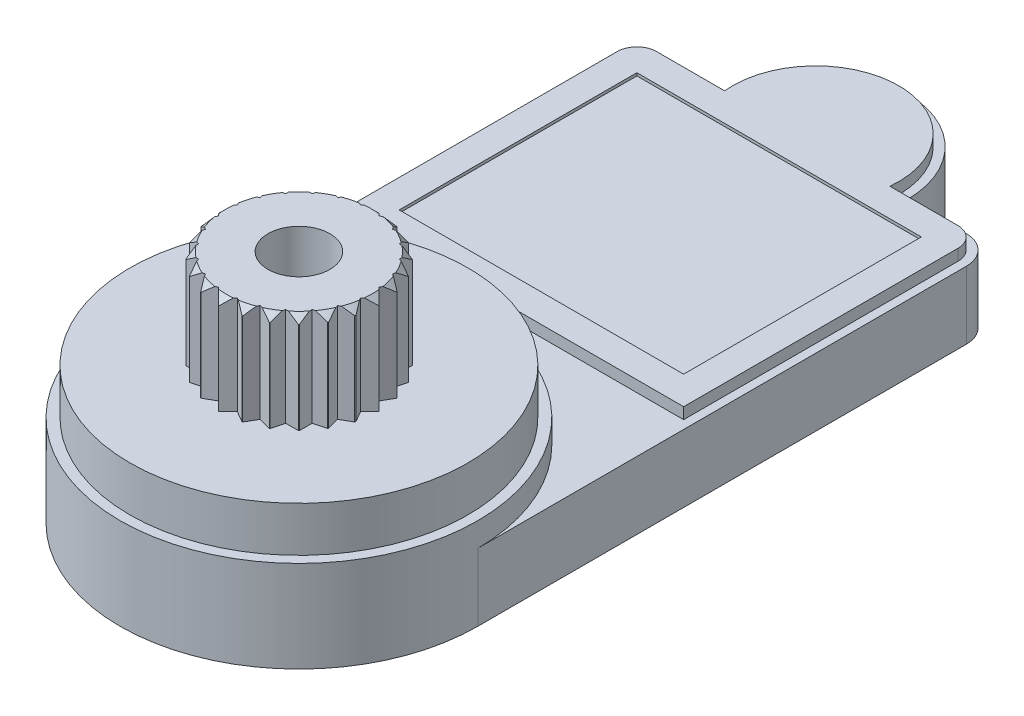
from build123d import *

# Parameters (mm, degrees)
SKETCH1_R           = 6.35
SKETCH1_R_2         = 1
BOSS_EXTRUDE1_DEPTH = 2.4
SKETCH2_R           = 6.35
BOSS_EXTRUDE2_DEPTH = 0.85
SKETCH3_R           = 6
BOSS_EXTRUDE3_DEPTH = 1.6
BOSS_EXTRUDE4_DEPTH = 3.5
SKETCH6_R           = 1.1
CUT_EXTRUDE1_DEPTH  = 4
BOSS_EXTRUDE5_DEPTH = 0.4
SKETCH8_W           = 10.1
SKETCH8_H           = 8.440176683
CUT_EXTRUDE2_DEPTH  = 0.1


with BuildPart() as part:
    # Sketch1 → Boss-Extrude1 (new body)
    with BuildSketch(Plane(origin=(0, 0, 0), x_dir=(1, 0, 0), z_dir=(0, 1, 0))):
        with Locations((0, -8.7)):
            Circle(SKETCH1_R)
        with BuildLine():
            Line((-3.25, 9.65), (-5.35, 9.65))
            ThreePointArc((-5.35, 9.65), (-4.642893219, 9.357106781), (-4.35, 8.65))
            ThreePointArc((-4.35, 8.65), (-5.350000006, 7.65), (-6.35, 8.650000012))
            Line((-6.35, 8.650000012), (-6.35, -8.700000013))
            ThreePointArc((-6.35, -8.700000013), (-7e-09, -2.35), (6.35, -8.7))
            Line((6.35, -8.7), (6.35, 8.65))
            ThreePointArc((6.35, 8.65), (4.642893215, 7.942893223), (5.350000012, 9.65))
            Line((5.350000012, 9.65), (3.25, 9.65))
            ThreePointArc((3.25, 9.65), (0, 6.4), (-3.25, 9.65))
        make_face()
        with Locations((-5.35, 8.65)):
            Circle(SKETCH1_R_2)
        with BuildLine():
            ThreePointArc((3.25, 9.65), (0, 12.9), (-3.25, 9.65))
            Line((-3.25, 9.65), (3.25, 9.65))
        make_face()
        with BuildLine():
            Line((3.25, 9.65), (-3.25, 9.65))
            ThreePointArc((-3.25, 9.65), (0, 6.4), (3.25, 9.65))
        make_face()
        with Locations((5.35, 8.65)):
            Circle(SKETCH1_R_2)
    extrude(amount=BOSS_EXTRUDE1_DEPTH)

    # Sketch2 → Boss-Extrude2 (add)
    with BuildSketch(Plane(origin=(0, 2.4, 0), x_dir=(-1, 0, 0), z_dir=(0, 1, 0))):
        with Locations((0, 8.7)):
            Circle(SKETCH2_R)
    extrude(amount=BOSS_EXTRUDE2_DEPTH)

    # Sketch3 → Boss-Extrude3 (add)
    with BuildSketch(Plane(origin=(0, 3.25, 0), x_dir=(-1, 0, 0), z_dir=(0, 1, 0))):
        with Locations((0, 8.7)):
            Circle(SKETCH3_R)
    extrude(amount=BOSS_EXTRUDE3_DEPTH)

    # Sketch4 → Boss-Extrude4 (add)
    with BuildSketch(Plane(origin=(0, 4.85, 0), x_dir=(-1, 0, 0), z_dir=(0, 1, 0))):
        Polygon((2.518440958, 8.368440958), (2.85, 8.7), (2.518440958, 9.031559042), (2.741390732, 9.417719379), (2.729517437, 9.451127629), (2.346813369, 9.672081926), (2.463209043, 10.106476495), (2.445926072, 10.130960886), (2.015254326, 10.246359032), (2.015254326, 10.700296057), (1.996868143, 10.715254326), (1.546359032, 10.715254326), (1.427678707, 11.15817533), (1.412422166, 11.16480218), (0.972081926, 11.046813369), (0.740314632, 11.448246096), (0.731654815, 11.44943636), (0.331559042, 11.218440958), (0, 11.55), (-0.331559042, 11.218440958), (-0.731654815, 11.44943636), (-0.740314632, 11.448246096), (-0.972081926, 11.046813369), (-1.412422166, 11.16480218), (-1.427678707, 11.15817533), (-1.546359032, 10.715254326), (-1.996868143, 10.715254326), (-2.015254326, 10.700296057), (-2.015254326, 10.246359032), (-2.445926072, 10.130960886), (-2.463209043, 10.106476495), (-2.346813369, 9.672081926), (-2.729517437, 9.451127629), (-2.741390732, 9.417719379), (-2.518440958, 9.031559042), (-2.85, 8.7), (-2.518440958, 8.368440958), (-2.752888605, 7.962365721), (-2.346813369, 7.727918074), (-2.468172401, 7.275), (-2.015254326, 7.153640968), (-2.015254326, 6.684745674), (-1.546359032, 6.684745674), (-1.425, 6.231827599), (-0.972081926, 6.353186631), (-0.737634279, 5.947111395), (-0.331559042, 6.181559042), (0, 5.85), (0.331559042, 6.181559042), (0.737634279, 5.947111395), (0.972081926, 6.353186631), (1.425, 6.231827599), (1.546359032, 6.684745674), (2.015254326, 6.684745674), (2.015254326, 7.153640968), (2.468172401, 7.275), (2.346813369, 7.727918074), (2.752888605, 7.962365721), align=None)
    extrude(amount=BOSS_EXTRUDE4_DEPTH)

    # Sketch5 → Cut-Revolve1 (revolve, cut)
    with BuildSketch(Plane(origin=(0, 0, 0), x_dir=(0, 0, -1), z_dir=(1, 0, 0))):
        Polygon((-6.9, 9.15), (-4.454839661, 9.15), (-4.454839661, 6.704839661), align=None)
    revolve(axis=Axis((0, 8.077813164, 8.7), (0, -1, 0)), mode=Mode.SUBTRACT)

    # Sketch6 → Cut-Extrude1 (cut)
    with BuildSketch(Plane(origin=(0, 8.35, 0), x_dir=(-1, 0, 0), z_dir=(0, 1, 0))):
        with Locations((0, 8.7)):
            Circle(SKETCH6_R)
    extrude(amount=-CUT_EXTRUDE1_DEPTH, mode=Mode.SUBTRACT)

    # Sketch7 → Boss-Extrude5 (add)
    with BuildSketch(Plane(origin=(0, 2.4, 0), x_dir=(-1, 0, 0), z_dir=(0, 1, 0))):
        with BuildLine():
            Line((2.934706118, -9.35), (5.35, -9.35))
            ThreePointArc((5.35, -9.35), (5.844974747, -9.144974747), (6.05, -8.65))
            Line((6.05, -8.65), (6.05, 1.090176683))
            Line((6.05, 1.090176683), (-6.05, 1.090176683))
            Line((-6.05, 1.090176683), (-6.05, -1.654552581))
            Line((-6.05, -1.654552581), (-6.05, -8.65))
            ThreePointArc((-6.05, -8.65), (-5.844974747, -9.144974747), (-5.35, -9.35))
            Line((-5.35, -9.35), (-2.934706118, -9.35))
            ThreePointArc((-2.934706118, -9.35), (0, -12.6), (2.934706118, -9.35))
        make_face()
    extrude(amount=BOSS_EXTRUDE5_DEPTH)

    # Sketch8 → Cut-Extrude2 (cut)
    with BuildSketch(Plane(origin=(0, 2.8, 0), x_dir=(-1, 0, 0), z_dir=(0, 1, 0))):
        with Locations((0, -4.129911659)):
            Rectangle(SKETCH8_W, SKETCH8_H)
    extrude(amount=-CUT_EXTRUDE2_DEPTH, mode=Mode.SUBTRACT)


solid = part.part
